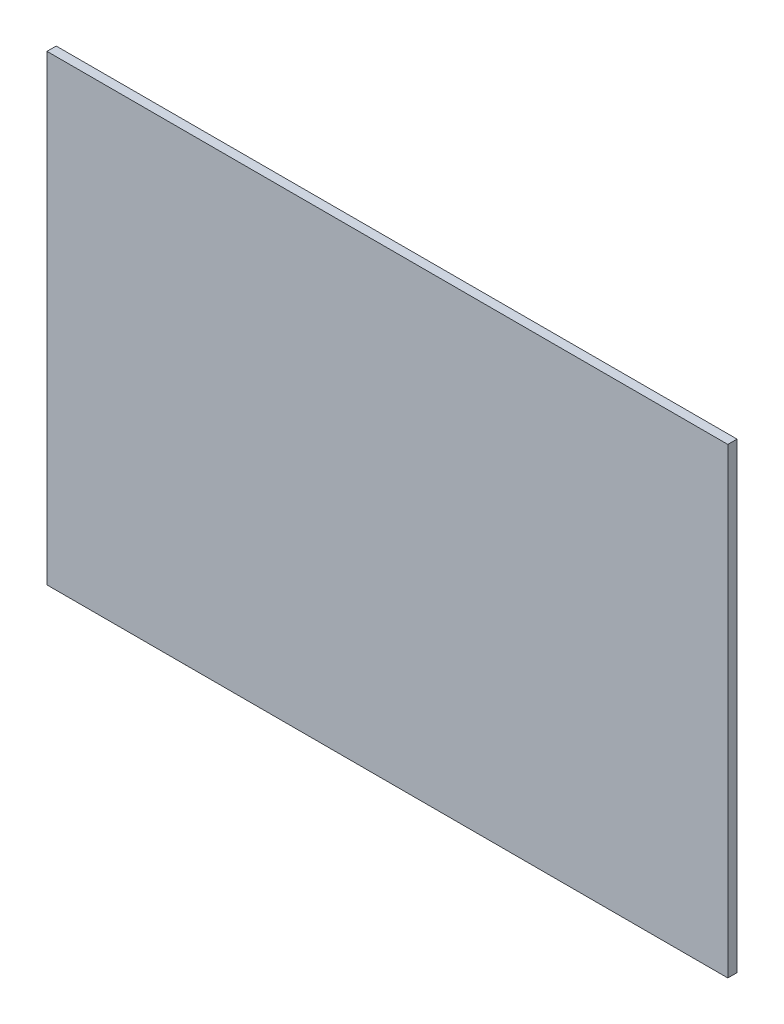
from build123d import *

# Parameters (mm, degrees)
SKETCH1_W           = 112.268
SKETCH1_H           = 76.2
BOSS_EXTRUDE1_DEPTH = 1.51892


with BuildPart() as part:
    # Sketch1 → Boss-Extrude1 (new body)
    with BuildSketch(Plane.XY):
        with Locations((56.134, 38.1)):
            Rectangle(SKETCH1_W, SKETCH1_H)
    extrude(amount=BOSS_EXTRUDE1_DEPTH)


solid = part.part
